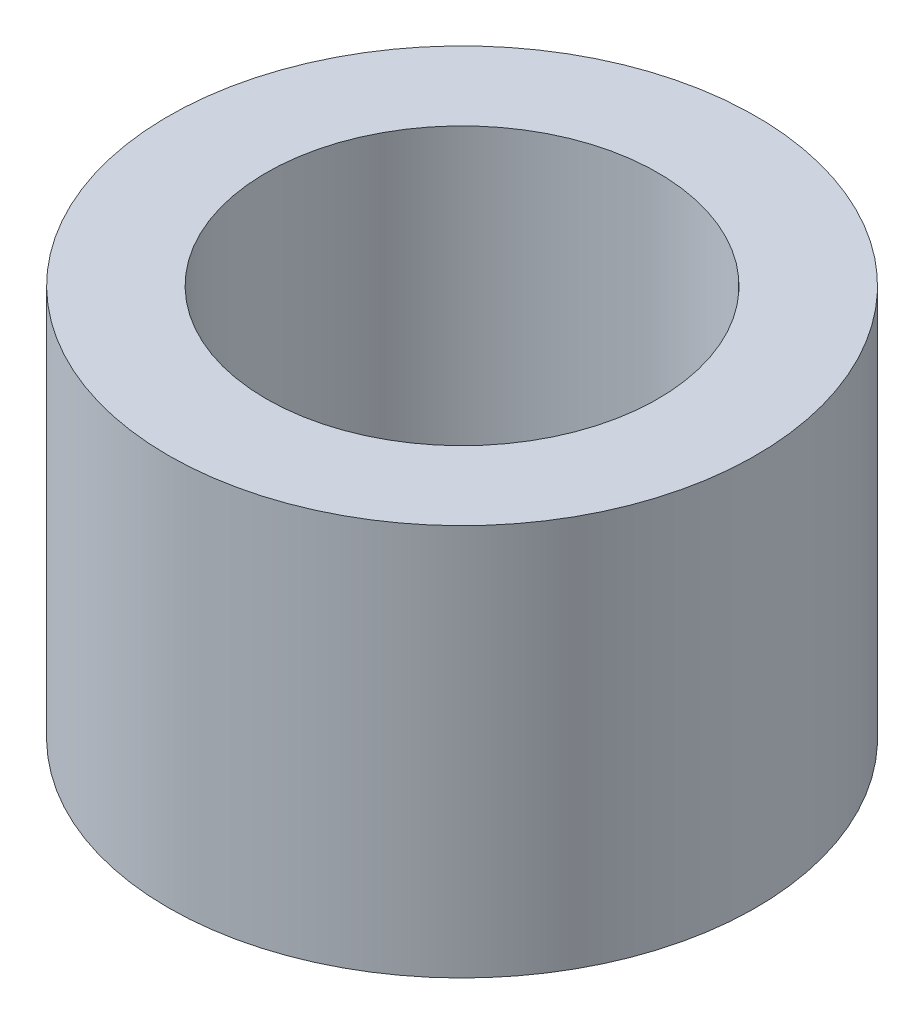
from build123d import *

# Parameters (mm, degrees)
SKETCH1_R           = 2.38125
SKETCH1_R_2         = 1.5875
BOSS_EXTRUDE1_DEPTH = 3.175


with BuildPart() as part:
    # Sketch1 → Boss-Extrude1 (new body)
    with BuildSketch(Plane(origin=(0, 0, 0), x_dir=(1, 0, 0), z_dir=(0, 1, 0))):
        Circle(SKETCH1_R)
        Circle(SKETCH1_R_2, mode=Mode.SUBTRACT)
    extrude(amount=BOSS_EXTRUDE1_DEPTH)


solid = part.part
